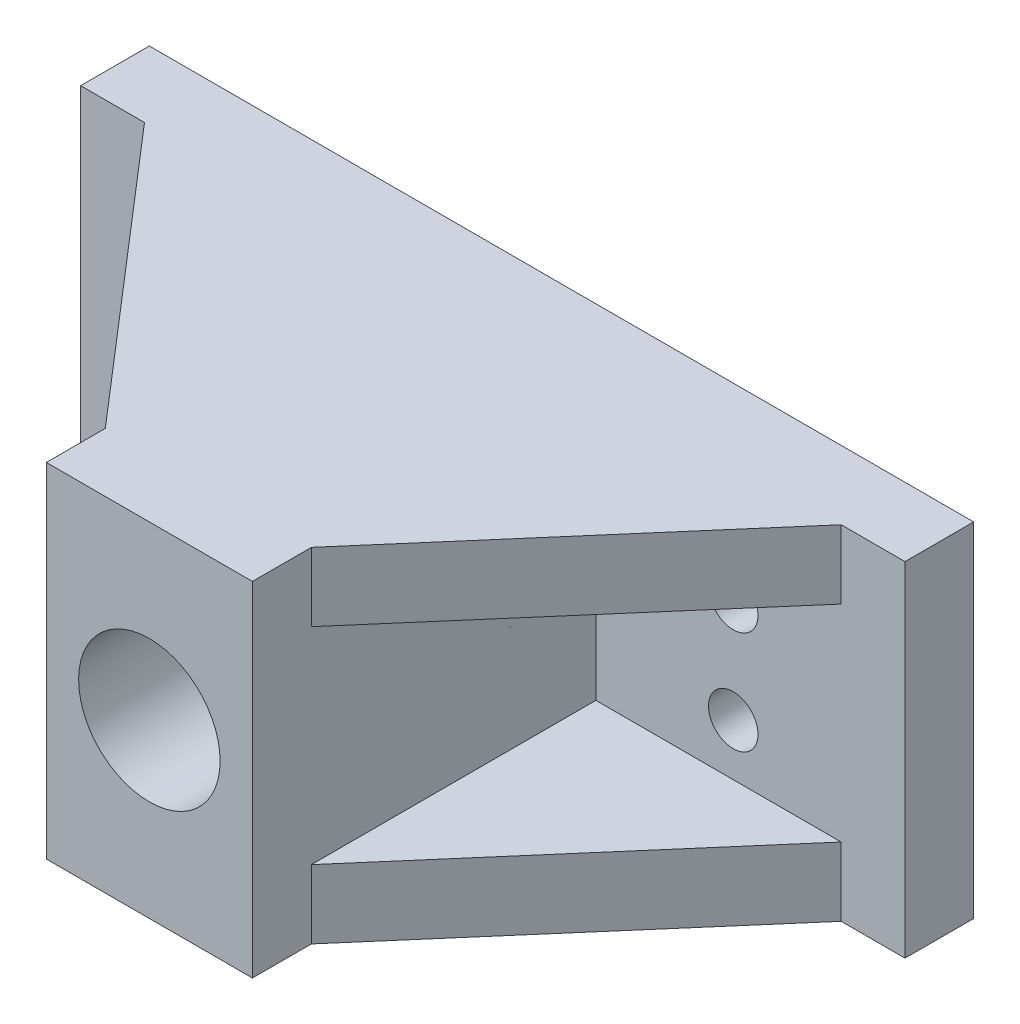
from build123d import *

# Parameters (mm, degrees)
SKETCH_1_W               = 40
SKETCH_1_H               = 15
EXTRUDE_1_DEPTH          = 5
SKETCH_2_R               = 5.15
SKETCH_2_R_2             = 1.8
CUT_EXTRUDE_1_DEPTH      = 5
SKETCH_3_W               = 15
SKETCH_3_H               = 15
SKETCH_3_R               = 5.05
EXTRUDE_2_DEPTH          = 25
SKETCH_4_R               = 5.5
CUT_EXTRUDE_2_DEPTH      = 31
SKETCH_5_W               = 10
SKETCH_5_H               = 15
EXTRUDE_3_DEPTH          = 5
SKETCH_6_R               = 1.8
CUT_EXTRUDE_3_DEPTH      = 5
SKETCH_7_W               = 60
SKETCH_7_H               = 5
EXTRUDE_4_DEPTH          = 5
SKETCH_8_W               = 15
SKETCH_8_H               = 5
EXTRUDE_5_DEPTH          = 25
RIB_1_REACH              = 51.244
SKETCH_9_WALL_W          = 127.83111072
SKETCH_9_WALL_H          = 5
MIRROR_2_COPY_1_REACH    = 51.244
MIRROR_2_COPY_1_SKETCH_W = 127.83111072
MIRROR_2_COPY_1_SKETCH_H = 5
SKETCH_11_R              = 1.8
EXTRUDE_6_DEPTH          = 5
SKETCH_12_R              = 1.8
CUT_EXTRUDE_4_DEPTH      = 5
SKETCH_13_R              = 5.5
SKETCH_13_R_2            = 5.15
EXTRUDE_7_DEPTH          = 25


with BuildPart() as part:
    # 草图1 → 凸台-拉伸1 (new body)
    with BuildSketch(Plane.XY):
        Rectangle(SKETCH_1_W, SKETCH_1_H)
    extrude(amount=EXTRUDE_1_DEPTH)

    # 草图2 → 切除-拉伸1 (cut)
    with BuildSketch(Plane.XY.offset(5)):
        Circle(SKETCH_2_R)
        with Locations((-12, 0)):
            Circle(SKETCH_2_R_2)
        with Locations(Location((12, 0, 0), (0, 0, 180))):
            Circle(SKETCH_2_R_2)
    extrude(amount=-CUT_EXTRUDE_1_DEPTH, mode=Mode.SUBTRACT)

    # 草图3 → 凸台-拉伸2 (add)
    with BuildSketch(Plane.XY.offset(5)):
        Rectangle(SKETCH_3_W, SKETCH_3_H)
        Circle(SKETCH_3_R, mode=Mode.SUBTRACT)
    extrude(amount=EXTRUDE_2_DEPTH)

    # 草图4 → 切除-拉伸2 (cut)
    with BuildSketch(Plane(origin=(0, 0, 5), x_dir=(-1, 0, 0), z_dir=(0, 0, -1))):
        Circle(SKETCH_4_R)
    extrude(amount=-CUT_EXTRUDE_2_DEPTH, mode=Mode.SUBTRACT)

    # 草图5 → 凸台-拉伸3 (add)
    with BuildSketch(Plane.XY.offset(5)):
        with Locations((-25, 0)):
            Rectangle(SKETCH_5_W, SKETCH_5_H)
        with Locations((25, 0)):
            Rectangle(SKETCH_5_W, SKETCH_5_H)
    extrude(amount=-EXTRUDE_3_DEPTH)

    # 草图6 → 切除-拉伸3 (cut)
    with BuildSketch(Plane.XY.offset(5)):
        with Locations((-24, 0)):
            Circle(SKETCH_6_R)
        with Locations(Location((24, 0, 0), (0, 0, 180))):
            Circle(SKETCH_6_R)
    extrude(amount=-CUT_EXTRUDE_3_DEPTH, mode=Mode.SUBTRACT)

    # 草图7 → 凸台-拉伸4 (add)
    with BuildSketch(Plane.XY.offset(5)):
        with Locations((0, 10)):
            Rectangle(SKETCH_7_W, SKETCH_7_H)
        with Locations((0, -10)):
            Rectangle(SKETCH_7_W, SKETCH_7_H)
    extrude(amount=-EXTRUDE_4_DEPTH)

    # 草图8 → 凸台-拉伸5 (add)
    with BuildSketch(Plane.XY.offset(5)):
        with Locations((0, 10)):
            Rectangle(SKETCH_8_W, SKETCH_8_H)
        with Locations((0, -10)):
            Rectangle(SKETCH_8_W, SKETCH_8_H)
    extrude(amount=EXTRUDE_5_DEPTH)

    # 草图9 wall → 筋1 (add, up to next)
    with BuildSketch(Plane(origin=(-16.427615827, 12.5, 15.353801199), x_dir=(0.653020400469, 0, 0.75734031754), z_dir=(0.75734031754, 0, -0.653020400469)), mode=Mode.PRIVATE) as rib_1_sk1:
        with Locations((0, 2.5)):
            Rectangle(SKETCH_9_WALL_W, SKETCH_9_WALL_H)
    rib_1_tool1 = extrude(rib_1_sk1.sketch, amount=RIB_1_REACH, mode=Mode.PRIVATE) - part.part
    rib_1 = rib_1_tool1.solids().sort_by_distance((-16.427615827, 12.5, 15.353801199))[0]
    add(rib_1)

    # 镜向1: 筋1 across plane
    add(rib_1.mirror(Plane.ZX))

    # 镜向2: 筋1 across plane
    add(rib_1.mirror(Plane.ZY))

    # 镜向2 copy 1 sketch → 镜向2 copy 1 (add, up to next)
    with BuildSketch(Plane(origin=(16.427615827, -12.5, 15.353801199), x_dir=(-0.653020400469, 0, 0.75734031754), z_dir=(-0.75734031754, 0, -0.653020400469)), mode=Mode.PRIVATE) as mirror_2_copy_1_sk1:
        with Locations((0, 2.5)):
            Rectangle(MIRROR_2_COPY_1_SKETCH_W, MIRROR_2_COPY_1_SKETCH_H)
    mirror_2_copy_1_tool1 = extrude(mirror_2_copy_1_sk1.sketch, amount=MIRROR_2_COPY_1_REACH, mode=Mode.PRIVATE) - part.part
    add(mirror_2_copy_1_tool1.solids().sort_by_distance((16.427615827, -12.5, 15.353801199))[0])

    # 草图11 → 凸台-拉伸6 (add)
    with BuildSketch(Plane.XY.offset(5)):
        with Locations((-24, 0)):
            Circle(SKETCH_11_R)
        with Locations((-12, 0)):
            Circle(SKETCH_11_R)
        with Locations((12, 0)):
            Circle(SKETCH_11_R)
        with Locations((24, 0)):
            Circle(SKETCH_11_R)
    extrude(amount=-EXTRUDE_6_DEPTH)

    # 草图12 → 切除-拉伸4 (cut)
    with BuildSketch(Plane.XY.offset(5)):
        with Locations((-17.5, 3.75)):
            Circle(SKETCH_12_R)
        with Locations(Location((-17.5, -3.75, 0), (0, 0, 180))):
            Circle(SKETCH_12_R)
        with Locations((17.5, -3.75)):
            Circle(SKETCH_12_R)
        with Locations(Location((17.5, 3.75, 0), (0, 0, 180))):
            Circle(SKETCH_12_R)
    extrude(amount=-CUT_EXTRUDE_4_DEPTH, mode=Mode.SUBTRACT)

    # 草图13 → 凸台-拉伸7 (add)
    with BuildSketch(Plane.XY.offset(5)):
        Circle(SKETCH_13_R)
        Circle(SKETCH_13_R_2, mode=Mode.SUBTRACT)
    extrude(amount=EXTRUDE_7_DEPTH)


solid = part.part
